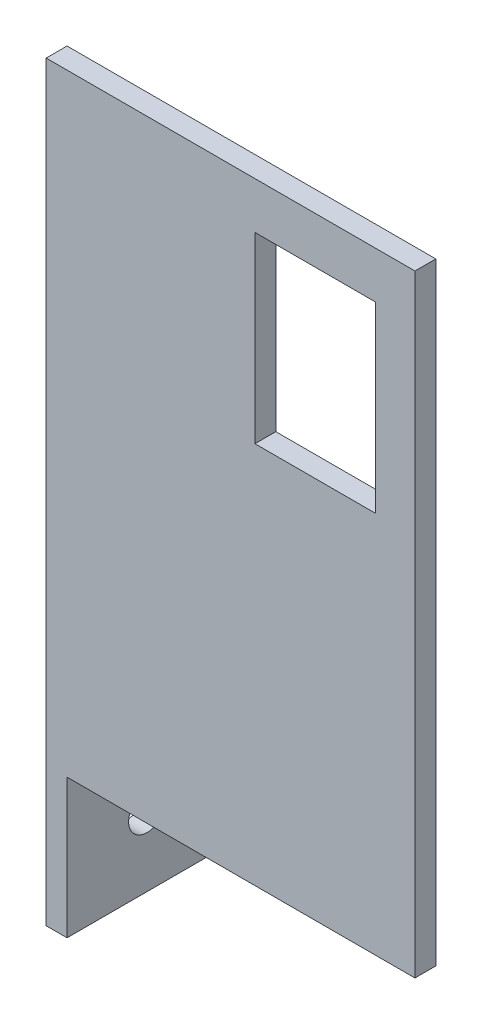
from build123d import *

# Parameters (mm, degrees)
SKETCH_1_W          = 23
SKETCH_1_H          = 23
EXTRUDE_1_DEPTH     = 3
SKETCH_3_R          = 2.65
CUT_EXTRUDE_1_DEPTH = 3
SKETCH_4_W          = 3
SKETCH_4_H          = 23
EXTRUDE_2_DEPTH     = 20
SKETCH_5_R          = 2.65
CUT_EXTRUDE_2_DEPTH = 20
SKETCH_6_W          = 23
SKETCH_6_H          = 3
EXTRUDE_3_DEPTH     = 85
SKETCH_7_W          = 3
SKETCH_7_H          = 88
EXTRUDE_4_DEPTH     = 30
SKETCH_8_W          = 17.3
SKETCH_8_H          = 26.3
CUT_EXTRUDE_3_DEPTH = 20


with BuildPart() as part:
    # 草图1 → 凸台-拉伸1 (new body)
    with BuildSketch(Plane(origin=(0, 0, 0), x_dir=(1, 0, 0), z_dir=(0, 1, 0))):
        with Locations((-3.136363636, -0.122994652)):
            Rectangle(SKETCH_1_W, SKETCH_1_H)
    extrude(amount=EXTRUDE_1_DEPTH)

    # 草图3 → 切除-拉伸1 (cut)
    with BuildSketch(Plane(origin=(0, 3, 0), x_dir=(1, 0, 0), z_dir=(0, 1, 0))):
        with Locations((-1.636363636, -0.122994652)):
            Circle(SKETCH_3_R)
    extrude(amount=-CUT_EXTRUDE_1_DEPTH, mode=Mode.SUBTRACT)

    # 草图4 → 凸台-拉伸2 (add)
    with BuildSketch(Plane.XZ):
        with Locations((-13.136363636, 0.122994652)):
            Rectangle(SKETCH_4_W, SKETCH_4_H)
    extrude(amount=EXTRUDE_2_DEPTH)

    # 草图5 → 切除-拉伸2 (cut)
    with BuildSketch(Plane(origin=(-11.636363636, 0, 0), x_dir=(0, 0, -1), z_dir=(1, 0, 0))):
        with Locations((-0.122994652, -10)):
            Circle(SKETCH_5_R)
    extrude(amount=-CUT_EXTRUDE_2_DEPTH, mode=Mode.SUBTRACT)

    # 草图6 → 凸台-拉伸3 (add)
    with BuildSketch(Plane(origin=(0, 3, 0), x_dir=(1, 0, 0), z_dir=(0, 1, 0))):
        with Locations((-3.136363636, -10.122994652)):
            Rectangle(SKETCH_6_W, SKETCH_6_H)
    extrude(amount=EXTRUDE_3_DEPTH)

    # 草图7 → 凸台-拉伸4 (add)
    with BuildSketch(Plane(origin=(8.363636364, 0, 0), x_dir=(0, 0, -1), z_dir=(1, 0, 0))):
        with Locations((-10.122994652, 44)):
            Rectangle(SKETCH_7_W, SKETCH_7_H)
    extrude(amount=EXTRUDE_4_DEPTH)

    # 草图8 → 切除-拉伸3 (cut)
    with BuildSketch(Plane(origin=(0, 0, 8.622994652), x_dir=(-1, 0, 0), z_dir=(0, 0, -1))):
        with Locations((-24.013636364, 68.15)):
            Rectangle(SKETCH_8_W, SKETCH_8_H)
    extrude(amount=-CUT_EXTRUDE_3_DEPTH, mode=Mode.SUBTRACT)


solid = part.part
